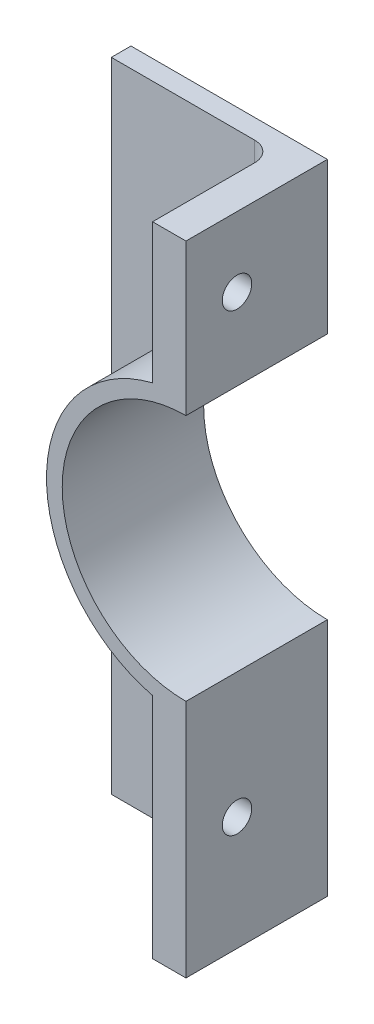
from build123d import *

# Parameters (mm, degrees)
BOSS_EXTRUDE2_DEPTH     = 2.54
BOSS_EXTRUDE3_DEPTH     = 18.288
FILLET1_R               = 2.54
CUT_EXTRUDE1_DEPTH      = 89.284276406
CUT_EXTRUDE1_DEPTH_BACK = 89.284276406
SKETCH4_R               = 1.905


with BuildPart() as part:
    # Sketch3 → Boss-Extrude2 (new body)
    with BuildSketch(Plane.XY):
        with BuildLine():
            Line((0, 82.55), (0, 0))
            Line((0, 0), (21.082, 0))
            Line((21.082, 0), (21.082, 29.480573053))
            ThreePointArc((21.082, 29.480573053), (7.366, 46.99), (21.082, 64.499426947))
            Line((21.082, 64.499426947), (21.082, 82.55))
            Line((21.082, 82.55), (0, 82.55))
        make_face()
    extrude(amount=BOSS_EXTRUDE2_DEPTH)

    # Sketch3_5 → Boss-Extrude3 (add)
    with BuildSketch(Plane.XY):
        with BuildLine():
            Line((21.082, 29.480573053), (21.082, 0))
            Line((21.082, 0), (25.4, 0))
            Line((25.4, 0), (25.4, 30.988))
            ThreePointArc((25.4, 30.988), (9.398, 46.99), (25.4, 62.992))
            Line((25.4, 62.992), (25.4, 82.55))
            Line((25.4, 82.55), (21.082, 82.55))
            Line((21.082, 82.55), (21.082, 64.499426947))
            ThreePointArc((21.082, 64.499426947), (7.366, 46.99), (21.082, 29.480573053))
        make_face()
    extrude(amount=BOSS_EXTRUDE3_DEPTH)

    # Fillet1
    fillet1_edges = [part.edges().sort_by_distance(p)[0] for p in [
        (21.082, 73.524713473, 2.54),
        (7.366, 46.99, 2.54),
        (21.082, 14.740286527, 2.54),
    ]]
    fillet(fillet1_edges, radius=FILLET1_R)

    # Sketch4 → Cut-Extrude1 (cut, two sides: drawn at the far end of the back side and taken through both)
    with BuildSketch(Plane(origin=(0, 0, 0), x_dir=(0, 0, -1), z_dir=(1, 0, 0)).offset(-CUT_EXTRUDE1_DEPTH_BACK)):
        with Locations((-11.684, 14.740286527)):
            Circle(SKETCH4_R)
        with Locations((-11.684, 73.524713473)):
            Circle(SKETCH4_R)
    extrude(amount=CUT_EXTRUDE1_DEPTH + CUT_EXTRUDE1_DEPTH_BACK, mode=Mode.SUBTRACT)


solid = part.part
